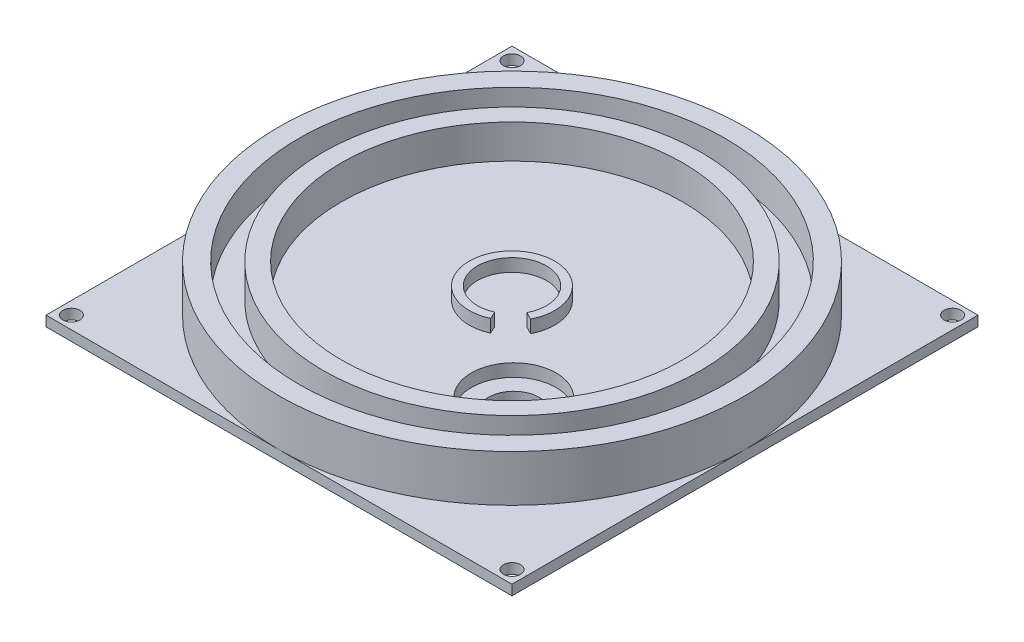
from build123d import *

# Parameters (mm, degrees)
SKETCH1_R           = 69.85
BOSS_EXTRUDE1_DEPTH = 3.81
SKETCH2_R           = 69.85
SKETCH2_R_2         = 63.881
SKETCH2_R_3         = 56.6547
SKETCH2_R_4         = 51.181
BOSS_EXTRUDE2_DEPTH = 10.16
SKETCH3_R           = 12.827
SKETCH3_R_2         = 10.3378
BOSS_EXTRUDE3_DEPTH = 3.81
CUT_EXTRUDE1_DEPTH  = 3.81
SKETCH5_R           = 12.7
CUT_EXTRUDE2_DEPTH  = 10.16
SKETCH6_W           = 139.7
SKETCH6_H           = 139.7
BOSS_EXTRUDE4_DEPTH = 3.048
SKETCH7_R           = 7.62
SKETCH7_R_2         = 2.54
CUT_EXTRUDE3_DEPTH  = 3.048


with BuildPart() as part:
    # Sketch1 → Boss-Extrude1 (new body)
    with BuildSketch(Plane(origin=(0, 0, 0), x_dir=(1, 0, 0), z_dir=(0, 1, 0))):
        Circle(SKETCH1_R)
    extrude(amount=BOSS_EXTRUDE1_DEPTH)

    # Sketch2 → Boss-Extrude2 (add)
    with BuildSketch(Plane(origin=(0, 3.81, 0), x_dir=(1, 0, 0), z_dir=(0, 1, 0))):
        Circle(SKETCH2_R)
        Circle(SKETCH2_R_2, mode=Mode.SUBTRACT)
        Circle(SKETCH2_R_3)
        Circle(SKETCH2_R_4, mode=Mode.SUBTRACT)
    extrude(amount=BOSS_EXTRUDE2_DEPTH)

    # Sketch3 → Boss-Extrude3 (add)
    with BuildSketch(Plane(origin=(0, 3.81, 0), x_dir=(1, 0, 0), z_dir=(0, 1, 0))):
        Circle(SKETCH3_R)
        Circle(SKETCH3_R_2, mode=Mode.SUBTRACT)
    extrude(amount=BOSS_EXTRUDE3_DEPTH)

    # Sketch4 → Cut-Extrude1 (cut)
    with BuildSketch(Plane(origin=(0, 7.62, 0), x_dir=(1, 0, 0), z_dir=(0, 1, 0))):
        with BuildLine():
            Line((4.238603881, -9.428910116), (5.259201376, -11.699261938))
            ThreePointArc((5.259201376, -11.699261938), (8.835496643, -9.29870572), (11.415504655, -5.849630969))
            Line((11.415504655, -5.849630969), (9.200218603, -4.714455058))
            ThreePointArc((9.200218603, -4.714455058), (7.120885413, -7.494204412), (4.238603881, -9.428910116))
        make_face()
    extrude(amount=-CUT_EXTRUDE1_DEPTH, mode=Mode.SUBTRACT)

    # Sketch5 → Cut-Extrude2 (cut)
    with BuildSketch(Plane(origin=(0, 3.81, 0), x_dir=(1, 0, 0), z_dir=(0, 1, 0))):
        with Locations((25.4, -24.886815787)):
            Circle(SKETCH5_R)
    extrude(amount=-CUT_EXTRUDE2_DEPTH, mode=Mode.SUBTRACT)

    # Sketch6 → Boss-Extrude4 (add)
    with BuildSketch(Plane.XZ):
        Rectangle(SKETCH6_W, SKETCH6_H)
    extrude(amount=BOSS_EXTRUDE4_DEPTH)

    # Sketch7 → Cut-Extrude3 (cut)
    with BuildSketch(Plane(origin=(0, 0, 0), x_dir=(1, 0, 0), z_dir=(0, 1, 0))):
        with Locations((25.4, -24.886815787)):
            Circle(SKETCH7_R)
        with Locations((-66.04, -66.04)):
            Circle(SKETCH7_R_2)
        with Locations((66.04, -66.04)):
            Circle(SKETCH7_R_2)
        with Locations((66.04, 66.04)):
            Circle(SKETCH7_R_2)
        with Locations((-66.04, 66.04)):
            Circle(SKETCH7_R_2)
    extrude(amount=-CUT_EXTRUDE3_DEPTH, mode=Mode.SUBTRACT)


solid = part.part
